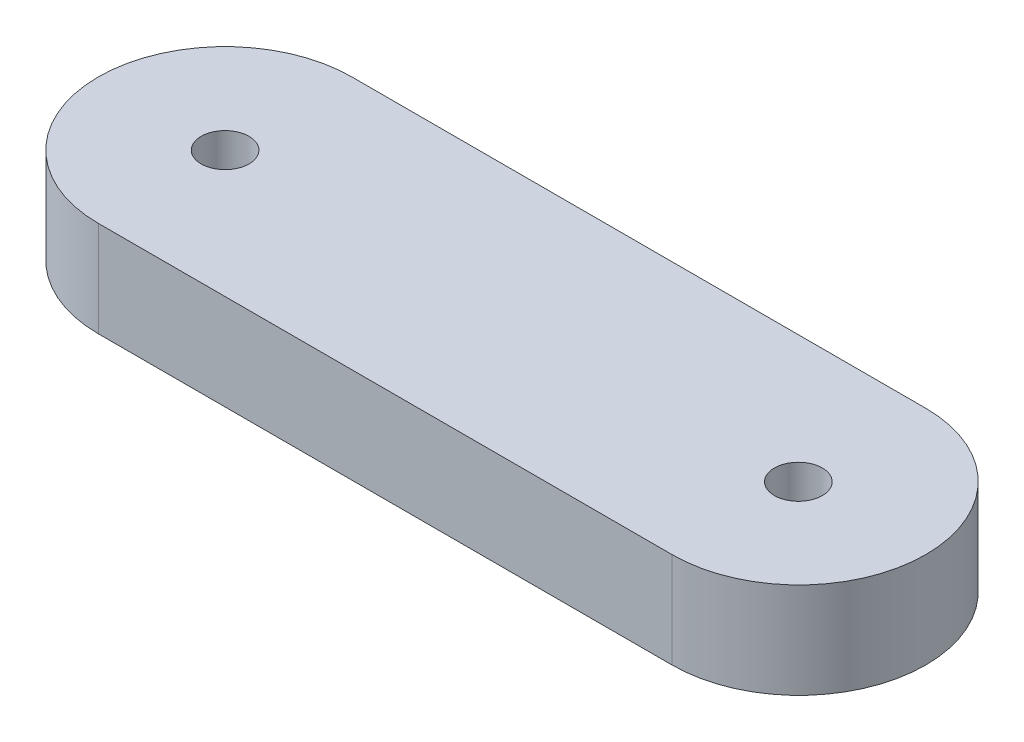
from build123d import *

# Parameters (mm, degrees)
SKETCH_1_R      = 1.501856065
EXTRUDE_1_DEPTH = 6


with BuildPart() as part:
    # Эскиз1 → Бобышка-Вытянуть1 (new body)
    with BuildSketch(Plane(origin=(0, 0, 0), x_dir=(1, 0, 0), z_dir=(0, 1, 0))):
        with BuildLine():
            Line((-16.408851954, 1.855177164), (19.591148045, 1.854908508))
            ThreePointArc((19.591148045, 1.854908508), (27.54533426, -6.099277706), (19.591148045, -14.053463921))
            Line((19.591148045, -14.053463921), (-16.408851954, -14.053463921))
            ThreePointArc((-16.408851954, -14.053463921), (-24.363172497, -6.099143379), (-16.408851954, 1.855177164))
        make_face()
        with Locations((19.591129693, -6.135494448)):
            Circle(SKETCH_1_R, mode=Mode.SUBTRACT)
        with Locations((-16.408851954, -6.099143379)):
            Circle(SKETCH_1_R, mode=Mode.SUBTRACT)
    extrude(amount=EXTRUDE_1_DEPTH)


solid = part.part
